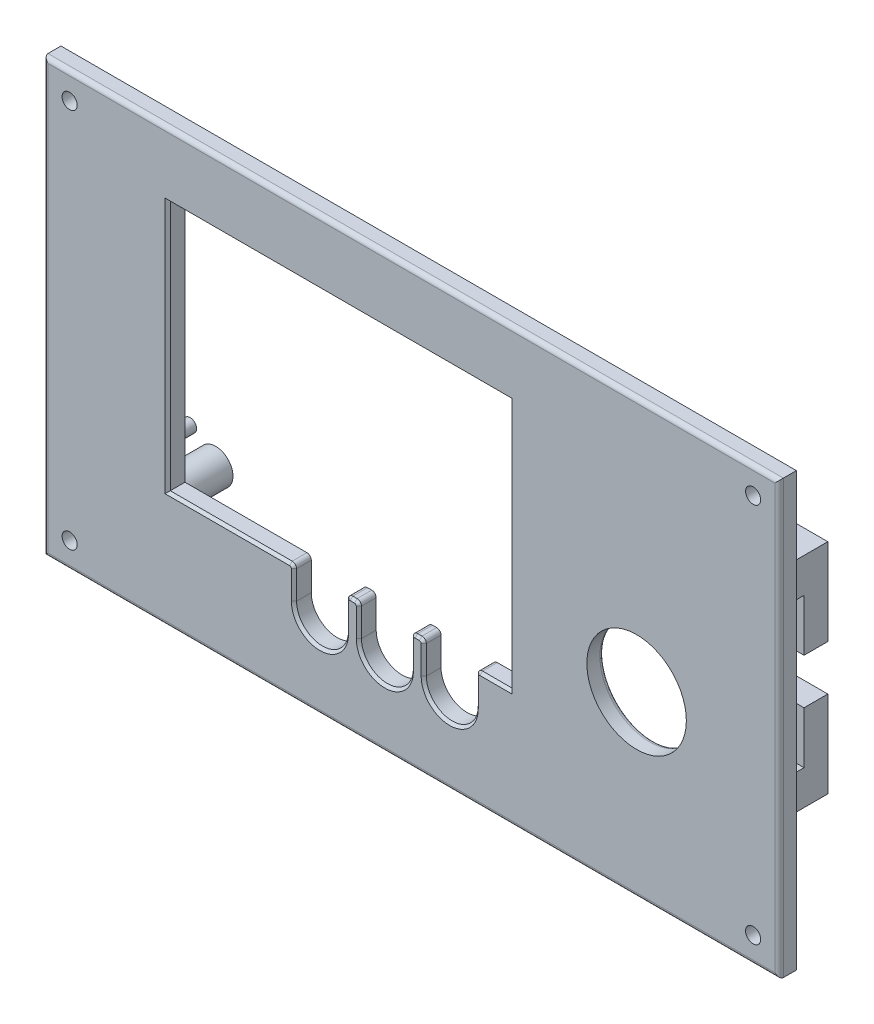
from build123d import *

# Parameters (mm, degrees)
SKETCH_1_W          = 170
SKETCH_1_H          = 100
SKETCH_1_R          = 11.5
SKETCH_1_R_2        = 1.75
EXTRUDE_1_DEPTH     = 4
CHAMFER_1_SIZE      = 0.6
FILLET_1_R          = 1
SKETCH_2_R          = 1.5
SKETCH_2_R_2        = 4
EXTRUDE_2_DEPTH     = 16
FILLET_2_R          = 1
SKETCH_3_W          = 12.665083531
SKETCH_3_H          = 63.992001
CUT_EXTRUDE_1_DEPTH = 85
SKETCH_4_W          = 10
SKETCH_4_H          = 20
SKETCH_4_R          = 1.5
EXTRUDE_3_DEPTH     = 22
SKETCH_5_W          = 16.5
SKETCH_5_H          = 34.5
CUT_EXTRUDE_2_DEPTH = 39
FILLET_3_R          = 2
FILLET_4_R          = 1


with BuildPart() as part:
    # 草图1 → 凸台-拉伸1 (new body)
    with BuildSketch(Plane.XY):
        with Locations((-10.173745174, -5.552123552)):
            Rectangle(SKETCH_1_W, SKETCH_1_H)
        with Locations((41.887773488, -14.352123552)):
            Circle(SKETCH_1_R, mode=Mode.SUBTRACT)
        with Locations((-89.173745174, 38.447876448)):
            Circle(SKETCH_1_R_2, mode=Mode.SUBTRACT)
        with Locations((68.826254826, 38.447876448)):
            Circle(SKETCH_1_R_2, mode=Mode.SUBTRACT)
        with Locations((68.826254826, -49.552123552)):
            Circle(SKETCH_1_R_2, mode=Mode.SUBTRACT)
        with Locations((-89.173745174, -49.552123552)):
            Circle(SKETCH_1_R_2, mode=Mode.SUBTRACT)
        with BuildLine():
            Line((-37.312226512, -36.052123552), (-37.312226512, -29.552123552))
            ThreePointArc((-37.312226512, -29.552123552), (-37.605119731, -28.845016771), (-38.312226512, -28.552123552))
            Line((-38.312226512, -28.552123552), (-66.512226512, -28.552123552))
            Line((-66.512226512, -28.552123552), (-66.512226512, 29.447876448))
            Line((-66.512226512, 29.447876448), (12.487773488, 29.447876448))
            Line((12.487773488, 29.447876448), (12.487773488, -28.552123552))
            Line((12.487773488, -28.552123552), (5.687773488, -28.552123552))
            ThreePointArc((5.687773488, -28.552123552), (4.980666707, -28.845016771), (4.687773488, -29.552123552))
            Line((4.687773488, -29.552123552), (4.687773488, -36.052123552))
            ThreePointArc((4.687773488, -36.052123552), (-1.312226512, -42.052123552), (-7.312226512, -36.052123552))
            Line((-7.312226512, -36.052123552), (-7.312226512, -29.552123552))
            ThreePointArc((-7.312226512, -29.552123552), (-7.605119731, -28.845016771), (-8.312226512, -28.552123552))
            Line((-8.312226512, -28.552123552), (-9.312226512, -28.552123552))
            ThreePointArc((-9.312226512, -28.552123552), (-10.019333293, -28.845016771), (-10.312226512, -29.552123552))
            Line((-10.312226512, -29.552123552), (-10.312226512, -36.052123552))
            ThreePointArc((-10.312226512, -36.052123552), (-16.312226512, -42.052123552), (-22.312226512, -36.052123552))
            Line((-22.312226512, -36.052123552), (-22.312226512, -29.552123552))
            ThreePointArc((-22.312226512, -29.552123552), (-22.605119731, -28.845016771), (-23.312226512, -28.552123552))
            Line((-23.312226512, -28.552123552), (-24.312226512, -28.552123552))
            ThreePointArc((-24.312226512, -28.552123552), (-25.019333293, -28.845016771), (-25.312226512, -29.552123552))
            Line((-25.312226512, -29.552123552), (-25.312226512, -36.052123552))
            ThreePointArc((-25.312226512, -36.052123552), (-31.312226512, -42.052123552), (-37.312226512, -36.052123552))
        make_face(mode=Mode.SUBTRACT)
    extrude(amount=EXTRUDE_1_DEPTH)

    # 倒角1
    chamfer_1_edges = [part.edges().sort_by_distance(p)[0] for p in [
        (-66.512226512, 0.447876448, 4),
        (-52.412226512, -28.552123552, 4),
        (-37.605119731, -28.845016771, 4),
        (-37.312226512, -32.802123552, 4),
        (-31.312226512, -42.052123552, 4),
        (-25.312226512, -32.802123552, 4),
        (-25.019333293, -28.845016771, 4),
        (-23.812226512, -28.552123552, 4),
        (-22.605119731, -28.845016771, 4),
        (-22.312226512, -32.802123552, 4),
        (-16.312226512, -42.052123552, 4),
        (-10.312226512, -32.802123552, 4),
        (-10.019333293, -28.845016771, 4),
        (-8.812226512, -28.552123552, 4),
        (-7.605119731, -28.845016771, 4),
        (-7.312226512, -32.802123552, 4),
        (-1.312226512, -42.052123552, 4),
        (4.687773488, -32.802123552, 4),
        (4.980666707, -28.845016771, 4),
        (9.087773488, -28.552123552, 4),
        (12.487773488, 0.447876448, 4),
        (-27.012226512, 29.447876448, 4),
    ]]
    chamfer(chamfer_1_edges, length=CHAMFER_1_SIZE)

    # 圆角1
    fillet_1_edges = [part.edges().sort_by_distance(p)[0] for p in [
        (30.387773488, -14.352123552, 0),
    ]]
    fillet(fillet_1_edges, radius=FILLET_1_R)

    # 草图2 → 凸台-拉伸2 (add)
    with BuildSketch(Plane(origin=(0, 0, 0), x_dir=(-1, 0, 0), z_dir=(0, 0, -1))):
        with Locations((-17.987773488, 25.397876448)):
            Circle(SKETCH_2_R)
        with Locations((73.312226512, 25.397876448)):
            Circle(SKETCH_2_R)
        with Locations((73.312226512, -24.502123552)):
            Circle(SKETCH_2_R)
        with Locations((-17.987773488, -24.502123552)):
            Circle(SKETCH_2_R)
        with Locations((75.412226512, -37.802123552)):
            Circle(SKETCH_2_R_2)
        with Locations((75.412226512, -37.802123552)):
            Circle(SKETCH_2_R, mode=Mode.SUBTRACT)
        with Locations((-10.687773488, -37.802123552)):
            Circle(SKETCH_2_R_2)
        with Locations((-10.687773488, -37.802123552)):
            Circle(SKETCH_2_R, mode=Mode.SUBTRACT)
    extrude(amount=EXTRUDE_2_DEPTH)

    # 圆角2
    fillet_2_edges = [part.edges().sort_by_distance(p)[0] for p in [
        (74.826254826, -5.552123552, 4),
        (-10.173745174, 44.447876448, 4),
        (-95.173745174, -5.552123552, 4),
        (-10.173745174, -55.552123552, 4),
    ]]
    fillet(fillet_2_edges, radius=FILLET_2_R)

    # 草图3 → 切除-拉伸1 (cut, symmetric)
    with BuildSketch(Plane(origin=(0, 0, 0), x_dir=(0, 0, -1), z_dir=(1, 0, 0))):
        with Locations((14.332541766, 2.780168245)):
            Rectangle(SKETCH_3_W, SKETCH_3_H)
    extrude(amount=CUT_EXTRUDE_1_DEPTH, both=True, mode=Mode.SUBTRACT)

    # 草图4 → 凸台-拉伸3 (add)
    with BuildSketch(Plane(origin=(0, 0, 0), x_dir=(-1, 0, 0), z_dir=(0, 0, -1))):
        with Locations((-55.087773488, 1.847876448)):
            Rectangle(SKETCH_4_W, SKETCH_4_H)
        with Locations((-55.087773488, -3.152123552)):
            Circle(SKETCH_4_R, mode=Mode.SUBTRACT)
        with Locations((-28.687773488, 1.847876448)):
            Rectangle(SKETCH_4_W, SKETCH_4_H)
        with Locations((-28.687773488, -3.152123552)):
            Circle(SKETCH_4_R, mode=Mode.SUBTRACT)
        with Locations((-55.087773488, -28.652123552)):
            Rectangle(SKETCH_4_W, SKETCH_4_H)
        with Locations((-55.087773488, -23.652123552)):
            Circle(SKETCH_4_R, mode=Mode.SUBTRACT)
    extrude(amount=EXTRUDE_3_DEPTH)

    # 草图5 → 切除-拉伸2 (cut)
    with BuildSketch(Plane(origin=(60.087773488, 0, 0), x_dir=(0, 0, -1), z_dir=(1, 0, 0))):
        with Locations((8.25, -13.402123552)):
            Rectangle(SKETCH_5_W, SKETCH_5_H)
    extrude(amount=-CUT_EXTRUDE_2_DEPTH, mode=Mode.SUBTRACT)

    # 圆角3
    fillet_3_edges = [part.edges().sort_by_distance(p)[0] for p in [
        (60.087773488, 7.847876448, 0),
        (55.087773488, 11.847876448, 0),
        (28.687773488, 11.847876448, 0),
        (33.687773488, 7.847876448, 0),
        (55.087773488, -38.652123552, 0),
        (50.087773488, -34.652123552, 0),
        (60.087773488, -34.652123552, 0),
        (23.687773488, 7.847876448, 0),
        (50.087773488, 7.847876448, 0),
        (55.087773488, 3.847876448, 0),
        (28.687773488, 3.847876448, 0),
        (55.087773488, -30.652123552, 0),
    ]]
    fillet(fillet_3_edges, radius=FILLET_3_R)

    # 圆角4
    fillet_4_edges = [part.edges().sort_by_distance(p)[0] for p in [
        (19.487773488, 25.397876448, 0),
        (-71.812226512, 25.397876448, 0),
        (-71.812226512, -24.502123552, 0),
        (19.487773488, -24.502123552, 0),
        (14.687773488, -37.802123552, 0),
    ]]
    fillet(fillet_4_edges, radius=FILLET_4_R)


solid = part.part
